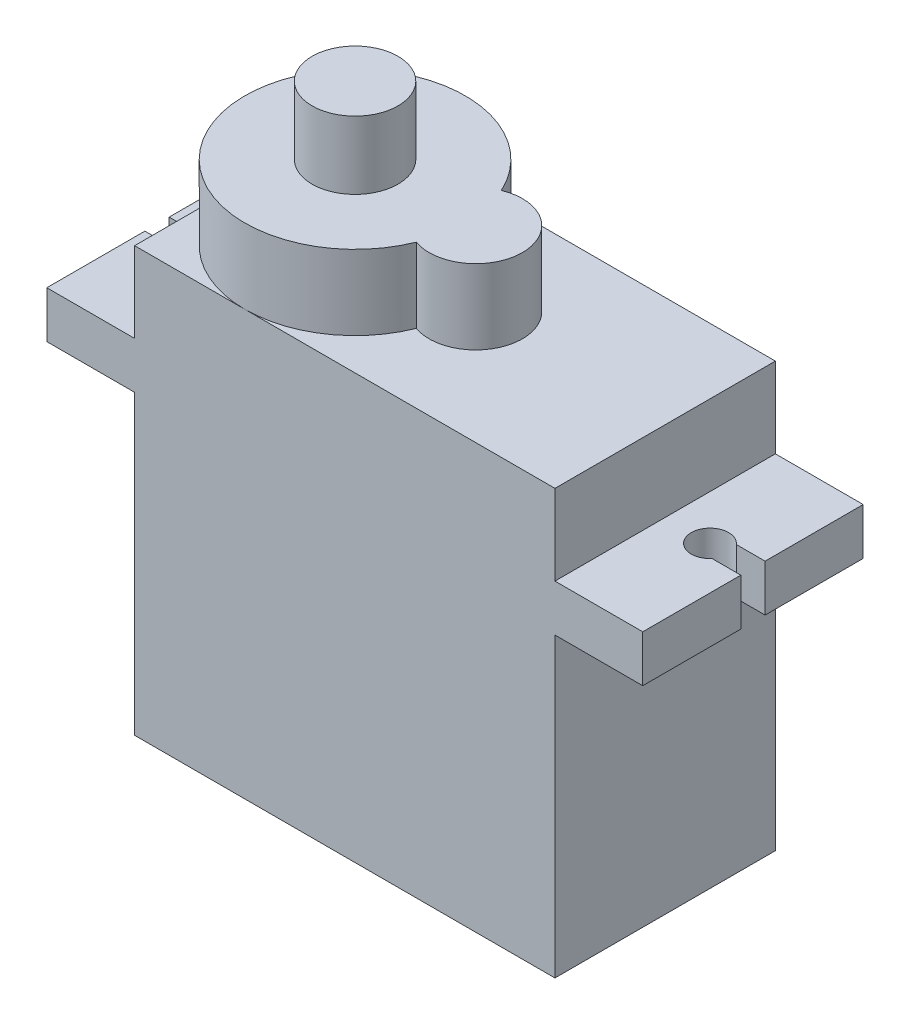
from build123d import *

# Parameters (mm, degrees)
BOSS_EXTRU_1_DEPTH      = 11.8
ESQUISSE2_R             = 5.9
BOSS_EXTRU_3_DEPTH      = 4
ESQUISSE3_R             = 2.5
BOSS_EXTRU_4_DEPTH      = 4
ESQUISSE5_R             = 2.3
BOSS_EXTRU_5_DEPTH      = 3.63
ENL_V_MAT_EXTRU_7_REACH = 20.4
ESQUISSE16_W            = 3.6
ESQUISSE16_H            = 1.2
BOSS_EXTRU_8_DEPTH      = 1.2


with BuildPart() as part:
    # Esquisse1 → Boss.-Extru.1 (new body)
    with BuildSketch(Plane.XY):
        Polygon((0, 0), (-22.5, 0), (-22.5, 15.9), (-27.2, 15.9), (-27.2, 18.4), (-22.5, 18.4), (-22.5, 22.7), (0, 22.7), (0, 18.4), (4.7, 18.4), (4.7, 15.9), (0, 15.9), align=None)
    extrude(amount=BOSS_EXTRU_1_DEPTH)

    # Esquisse2 → Boss.-Extru.3 (add)
    with BuildSketch(Plane(origin=(0, 22.7, 0), x_dir=(1, 0, 0), z_dir=(0, 1, 0))):
        with Locations((-16.6, -5.9)):
            Circle(ESQUISSE2_R)
    extrude(amount=BOSS_EXTRU_3_DEPTH)

    # Esquisse3 → Boss.-Extru.4 (add)
    with BuildSketch(Plane(origin=(0, 22.7, 0), x_dir=(1, 0, 0), z_dir=(0, 1, 0))):
        with Locations((-10.3, -5.738368037)):
            Circle(ESQUISSE3_R)
    extrude(amount=BOSS_EXTRU_4_DEPTH)

    # Esquisse5 → Boss.-Extru.5 (add)
    with BuildSketch(Plane(origin=(0, 26.7, 0), x_dir=(1, 0, 0), z_dir=(0, 1, 0))):
        with Locations((-16.6, -5.9)):
            Circle(ESQUISSE5_R)
    extrude(amount=BOSS_EXTRU_5_DEPTH)

    # Esquisse6 → Enlèv. mat.-Extru.7 (cut, up to next)
    with BuildSketch(Plane(origin=(0, 18.4, 0), x_dir=(1, 0, 0), z_dir=(0, 1, 0)), mode=Mode.PRIVATE) as enl_v_mat_extru_7_sk1:
        with BuildLine():
            Line((6.661887407, -5.9), (6.661887407, -5.25))
            Line((6.661887407, -5.25), (3.159934208, -5.25))
            ThreePointArc((3.159934208, -5.25), (1.4, -5.9), (3.159934208, -6.55))
            Line((3.159934208, -6.55), (6.661887407, -6.55))
            Line((6.661887407, -6.55), (6.661887407, -5.9))
        make_face()
    enl_v_mat_extru_7_tool1 = extrude(enl_v_mat_extru_7_sk1.sketch, amount=-ENL_V_MAT_EXTRU_7_REACH, mode=Mode.PRIVATE) & part.part
    add(enl_v_mat_extru_7_tool1.solids().sort_by_distance((3.903633, 18.4, 5.9))[0], mode=Mode.SUBTRACT)
    # Esquisse6 → Enlèv. mat.-Extru.7 (cut, up to next)
    with BuildSketch(Plane(origin=(0, 18.4, 0), x_dir=(1, 0, 0), z_dir=(0, 1, 0)), mode=Mode.PRIVATE) as enl_v_mat_extru_7_sk2:
        with BuildLine():
            Line((-29.161887407, -5.25), (-25.659934208, -5.25))
            ThreePointArc((-25.659934208, -5.25), (-23.9, -5.9), (-25.659934208, -6.55))
            Line((-25.659934208, -6.55), (-29.161887407, -6.55))
            Line((-29.161887407, -6.55), (-29.161887407, -5.9))
            Line((-29.161887407, -5.9), (-29.161887407, -5.25))
        make_face()
    enl_v_mat_extru_7_tool2 = extrude(enl_v_mat_extru_7_sk2.sketch, amount=-ENL_V_MAT_EXTRU_7_REACH, mode=Mode.PRIVATE) & part.part
    add(enl_v_mat_extru_7_tool2.solids().sort_by_distance((-26.403633, 18.4, 5.9))[0], mode=Mode.SUBTRACT)

    # Esquisse16 → Boss.-Extru.8 (add)
    with BuildSketch(Plane.ZY.offset(22.5)):
        with Locations((5.9, 5.1)):
            Rectangle(ESQUISSE16_W, ESQUISSE16_H)
    extrude(amount=BOSS_EXTRU_8_DEPTH)


solid = part.part
